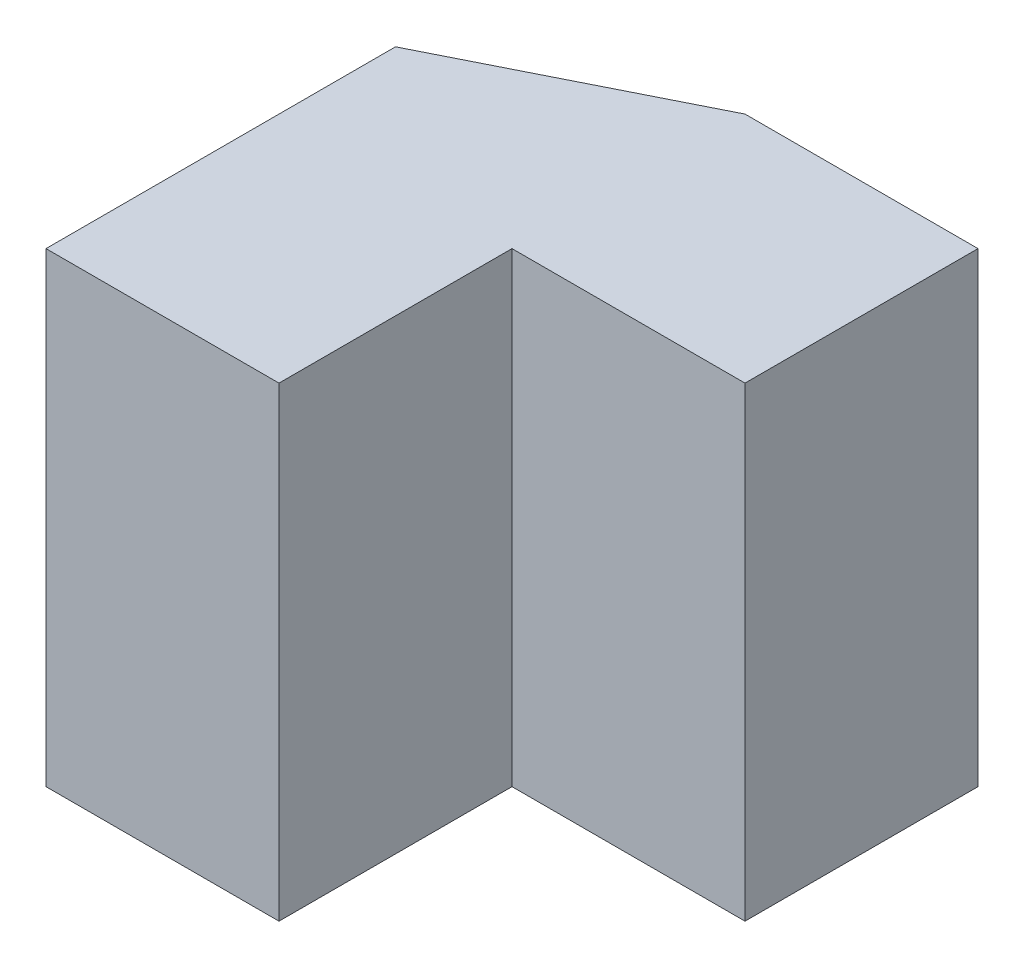
from build123d import *

# Parameters (mm, degrees)
SKETCH1_W           = 20
SKETCH1_H           = 20
BOSS_EXTRUDE1_DEPTH = 20
SKETCH2_W           = 10
SKETCH2_H           = 10
CUT_EXTRUDE1_DEPTH  = 20
CUT_EXTRUDE2_DEPTH  = 20


with BuildPart() as part:
    # Sketch1 → Boss-Extrude1 (new body)
    with BuildSketch(Plane.XY):
        with Locations((10, 10)):
            Rectangle(SKETCH1_W, SKETCH1_H)
    extrude(amount=BOSS_EXTRUDE1_DEPTH)

    # Sketch2 → Cut-Extrude1 (cut)
    with BuildSketch(Plane(origin=(0, 20, 0), x_dir=(1, 0, 0), z_dir=(0, 1, 0))):
        with Locations((15, -15)):
            Rectangle(SKETCH2_W, SKETCH2_H)
    extrude(amount=-CUT_EXTRUDE1_DEPTH, mode=Mode.SUBTRACT)

    # Sketch3 → Cut-Extrude2 (cut)
    with BuildSketch(Plane(origin=(0, 20, 0), x_dir=(1, 0, 0), z_dir=(0, 1, 0))):
        Polygon((0, 0), (10, 0), (0, -5), align=None)
    extrude(amount=-CUT_EXTRUDE2_DEPTH, mode=Mode.SUBTRACT)


solid = part.part
